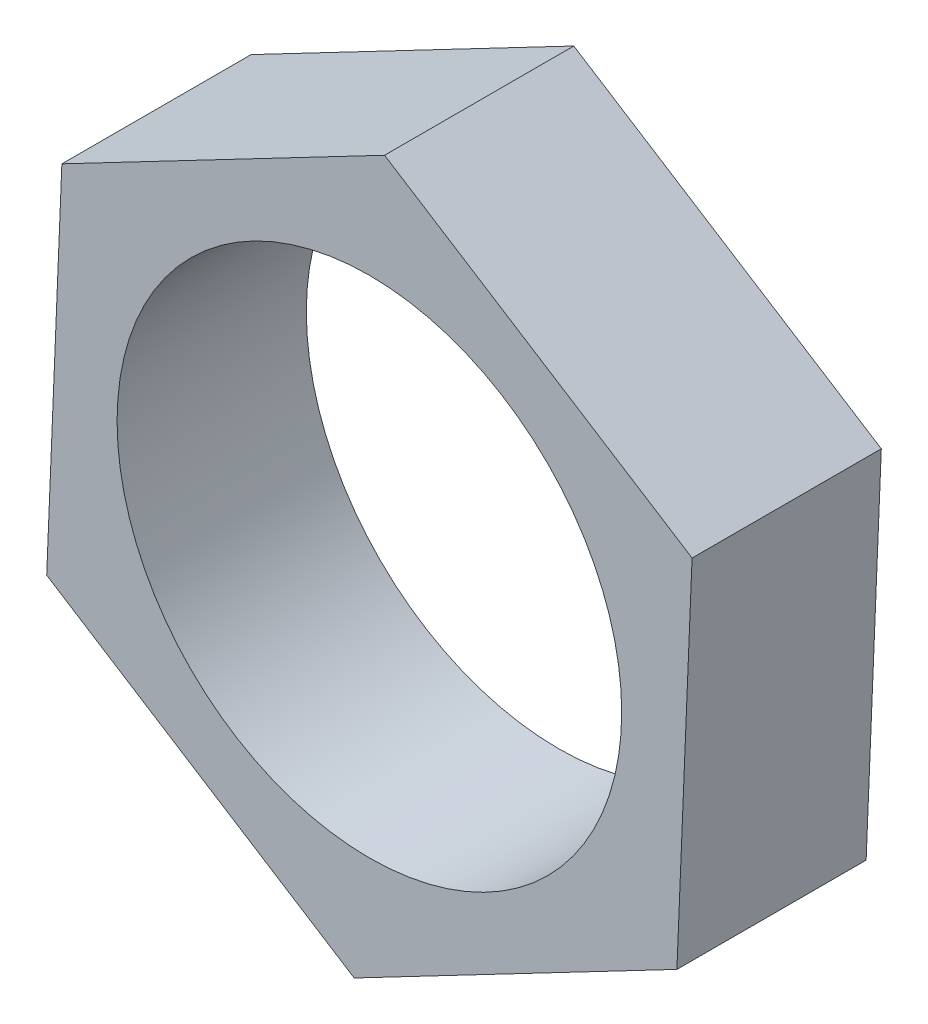
from build123d import *

# Parameters (mm, degrees)
EXTRUDE_1_DEPTH     = 3
SKETCH_2_R          = 4
CUT_EXTRUDE_1_DEPTH = 3


with BuildPart() as part:
    # 草图1 → 凸台-拉伸1 (new body)
    with BuildSketch(Plane.XY):
        Polygon((4.875371166, -3.092586187), (5.115943785, 2.675902189), (0.240572619, 5.768488376), (-4.875371166, 3.092586187), (-5.115943785, -2.675902189), (-0.240572619, -5.768488376), align=None)
    extrude(amount=EXTRUDE_1_DEPTH)

    # 草图2 → 切除-拉伸1 (cut)
    with BuildSketch(Plane.XY.offset(3)):
        Circle(SKETCH_2_R)
    extrude(amount=-CUT_EXTRUDE_1_DEPTH, mode=Mode.SUBTRACT)


solid = part.part
